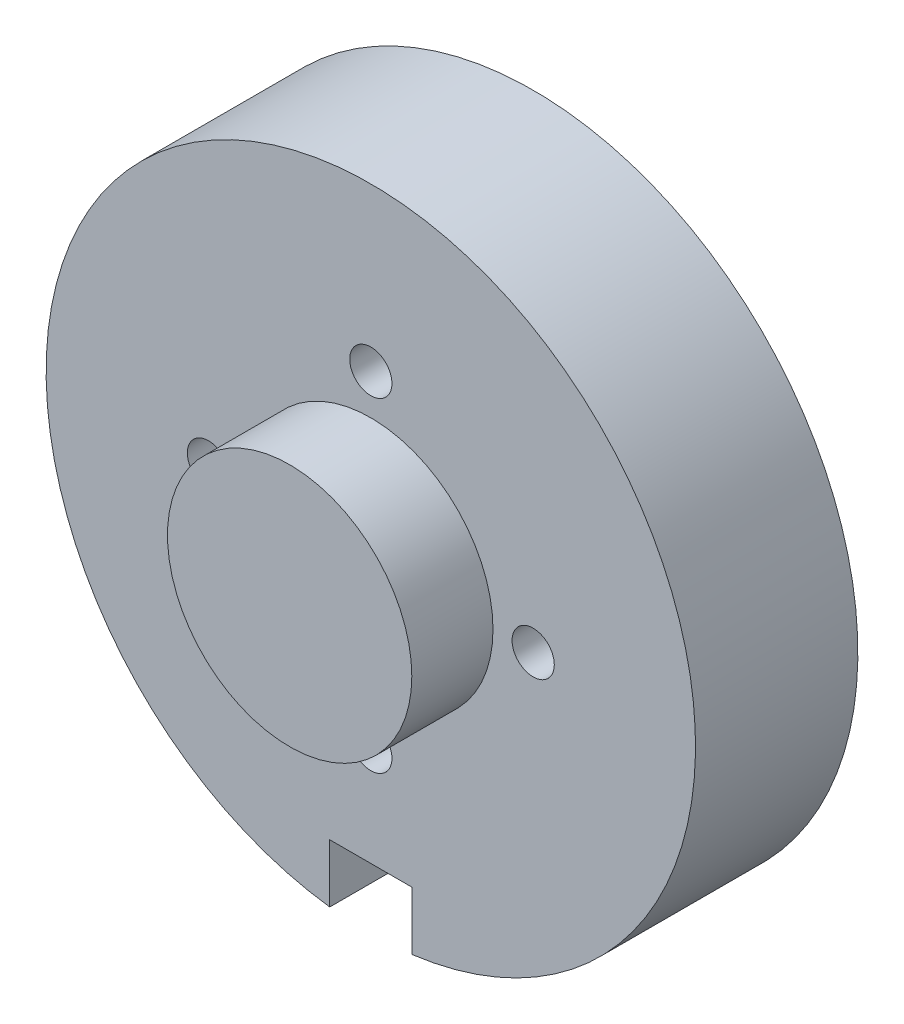
from build123d import *

# Parameters (mm, degrees)
SKETCH1_R           = 3.302
BOSS_EXTRUDE1_DEPTH = 25.4
SKETCH1_4_R         = 19.1135
BOSS_EXTRUDE2_DEPTH = 12.7


with BuildPart() as part:
    # Sketch1 → Boss-Extrude1 (new body)
    with BuildSketch(Plane.XY):
        with BuildLine():
            Line((-6.4262, -50.391903651), (-6.4262, -41.275))
            Line((-6.4262, -41.275), (6.4262, -41.275))
            Line((6.4262, -41.275), (6.4262, -50.391903651))
            ThreePointArc((6.4262, -50.391903651), (0, 50.8), (-6.4262, -50.391903651))
        make_face()
        with Locations((-25.4, 0)):
            Circle(SKETCH1_R, mode=Mode.SUBTRACT)
        with Locations((0, -25.4)):
            Circle(SKETCH1_R, mode=Mode.SUBTRACT)
        with Locations((25.4, 0)):
            Circle(SKETCH1_R, mode=Mode.SUBTRACT)
        with Locations((0, 25.4)):
            Circle(SKETCH1_R, mode=Mode.SUBTRACT)
    extrude(amount=-BOSS_EXTRUDE1_DEPTH)

    # Sketch1_4 → Boss-Extrude2 (add)
    with BuildSketch(Plane.XY):
        Circle(SKETCH1_4_R)
    extrude(amount=BOSS_EXTRUDE2_DEPTH)


solid = part.part
